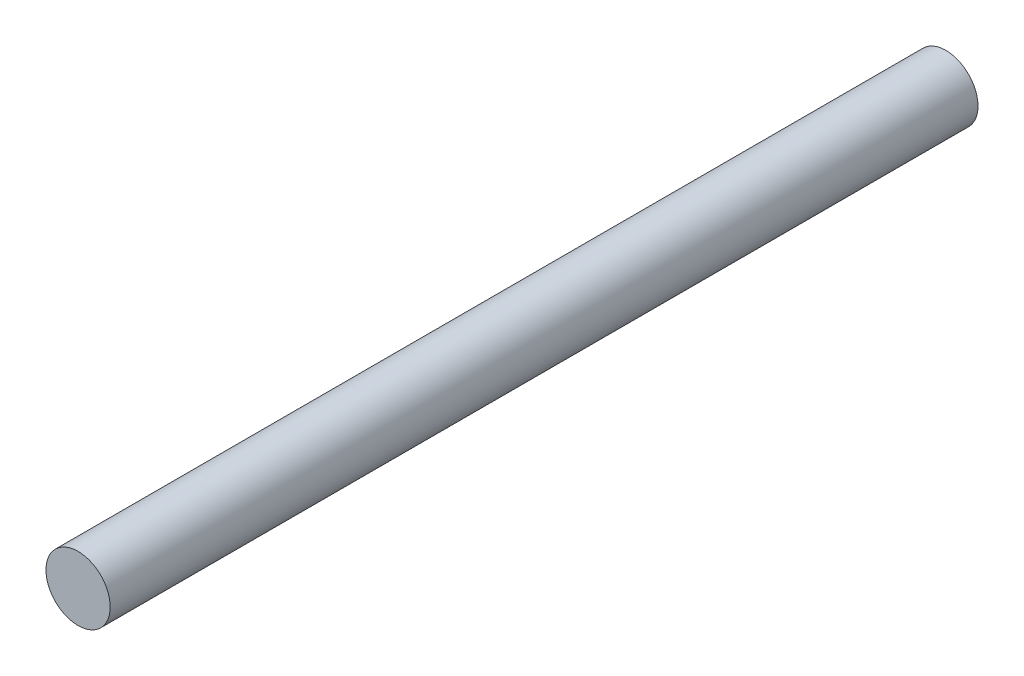
from build123d import *

# Parameters (mm, degrees)
ESQUISSE1_R        = 10
BOSS_EXTRU_1_DEPTH = 270


with BuildPart() as part:
    # Esquisse1 → Boss.-Extru.1 (new body)
    with BuildSketch(Plane.XY):
        Circle(ESQUISSE1_R)
    extrude(amount=BOSS_EXTRU_1_DEPTH)


solid = part.part
